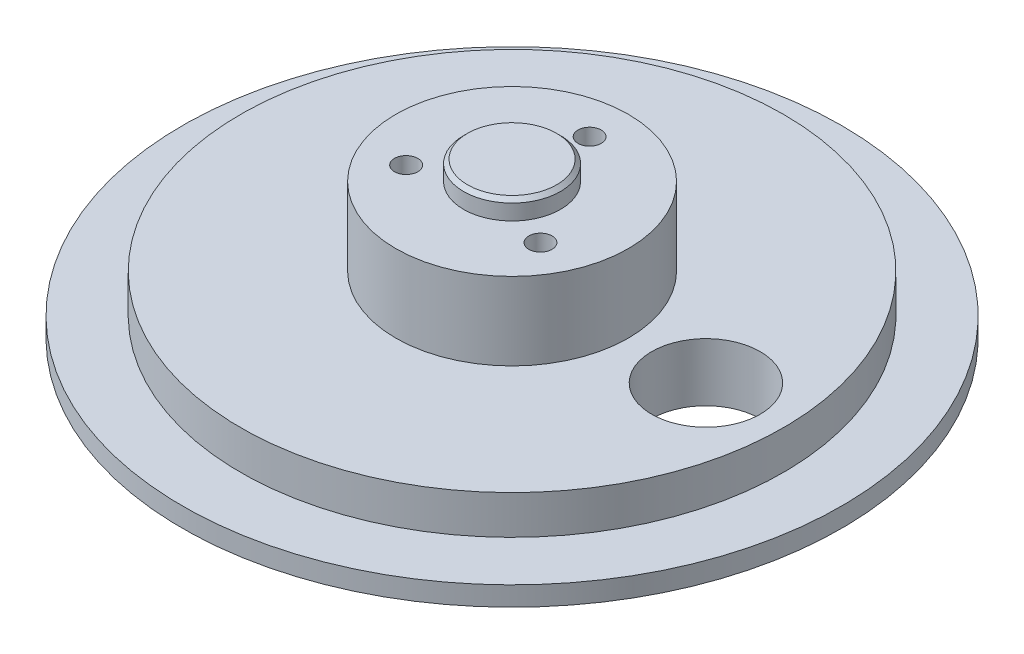
from build123d import *

# Parameters (mm, degrees)
SKETCH_2_R          = 14
CUT_EXTRUDE_1_DEPTH = 20
SKETCH_3_R          = 30
EXTRUDE_1_DEPTH     = 20
SKETCH_4_R          = 12.5
EXTRUDE_2_DEPTH     = 5
CHAMFER_1_SIZE      = 1
SKETCH_5_R          = 3
CUT_EXTRUDE_2_DEPTH = 15


with BuildPart() as part:
    # 草图1 → 旋转1 (revolve)
    with BuildSketch(Plane.XY):
        Polygon((0, 0), (0, 15), (-70, 15), (-70, 5), (-85, 5), (-85, 0), align=None)
    revolve(axis=Axis((0, 0, 0), (0, 1, 0)))

    # 草图2 → 切除-拉伸1 (cut)
    with BuildSketch(Plane(origin=(0, 0, 0), x_dir=(1, 0, 0), z_dir=(0, 1, 0))):
        with Locations((50, 0)):
            Circle(SKETCH_2_R)
    extrude(amount=CUT_EXTRUDE_1_DEPTH, mode=Mode.SUBTRACT)

    # 草图3 → 凸台-拉伸1 (add)
    with BuildSketch(Plane(origin=(0, 15, 0), x_dir=(1, 0, 0), z_dir=(0, 1, 0))):
        Circle(SKETCH_3_R)
    extrude(amount=EXTRUDE_1_DEPTH)

    # 草图4 → 凸台-拉伸2 (add)
    with BuildSketch(Plane(origin=(0, 35, 0), x_dir=(1, 0, 0), z_dir=(0, 1, 0))):
        Circle(SKETCH_4_R)
    extrude(amount=EXTRUDE_2_DEPTH)

    # 倒角1
    chamfer_1_edges = [part.edges().sort_by_distance(p)[0] for p in [
        (-12.5, 40, 0),
    ]]
    chamfer(chamfer_1_edges, length=CHAMFER_1_SIZE)

    # 草图5 → 切除-拉伸2 (cut)
    with BuildSketch(Plane(origin=(0, 35, 0), x_dir=(1, 0, 0), z_dir=(0, 1, 0))):
        with Locations((0, 20)):
            Circle(SKETCH_5_R)
        with Locations((17.320508076, -10)):
            Circle(SKETCH_5_R)
        with Locations((-17.320508076, -10)):
            Circle(SKETCH_5_R)
    extrude(amount=-CUT_EXTRUDE_2_DEPTH, mode=Mode.SUBTRACT)


solid = part.part
